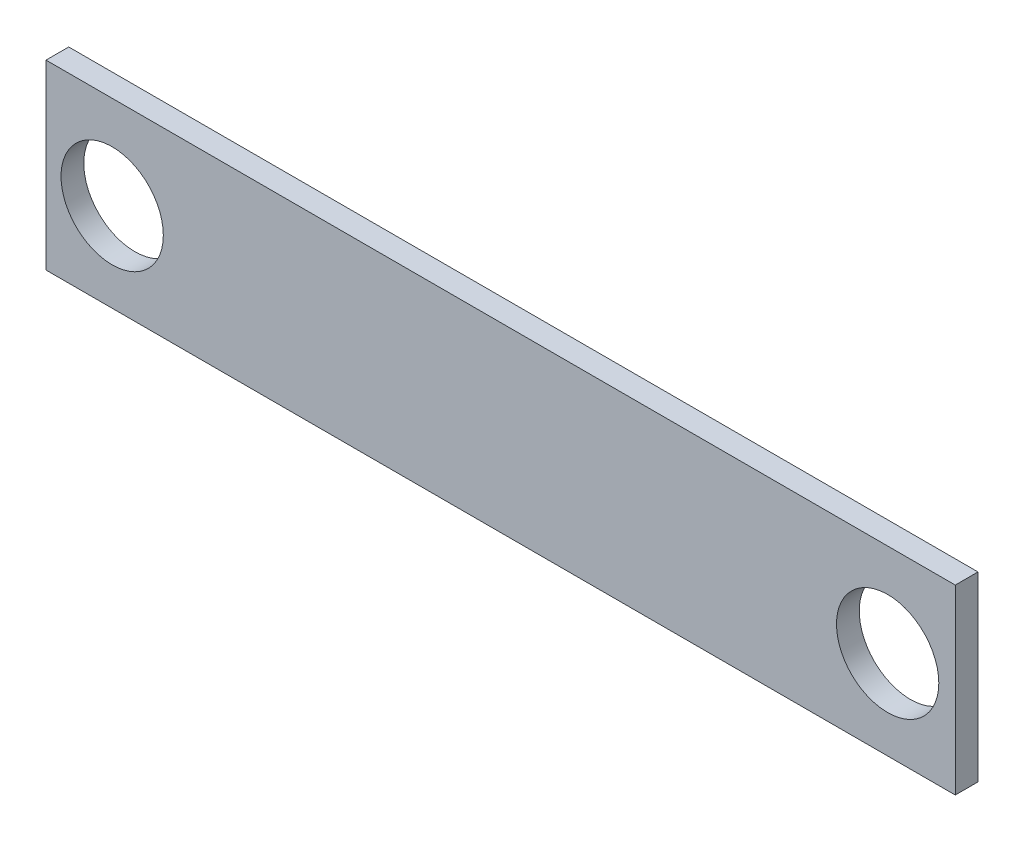
from build123d import *

# Parameters (mm, degrees)
SKETCH1_W           = 254
SKETCH1_H           = 50.8
BOSS_EXTRUDE1_DEPTH = 6.35
SKETCH3_R           = 14.2875
CUT_EXTRUDE1_DEPTH  = 6.35


with BuildPart() as part:
    # Sketch1 → Boss-Extrude1 (new body)
    with BuildSketch(Plane.XY):
        with Locations((-3.684873839, 24.231939799)):
            Rectangle(SKETCH1_W, SKETCH1_H)
    extrude(amount=BOSS_EXTRUDE1_DEPTH)

    # Sketch3 → Cut-Extrude1 (cut)
    with BuildSketch(Plane.XY.offset(6.35)):
        with Locations((-112.202147571, 23.62444568)):
            Circle(SKETCH3_R)
        with Locations((104.426951424, 23.62444568)):
            Circle(SKETCH3_R)
    extrude(amount=-CUT_EXTRUDE1_DEPTH, mode=Mode.SUBTRACT)


solid = part.part
